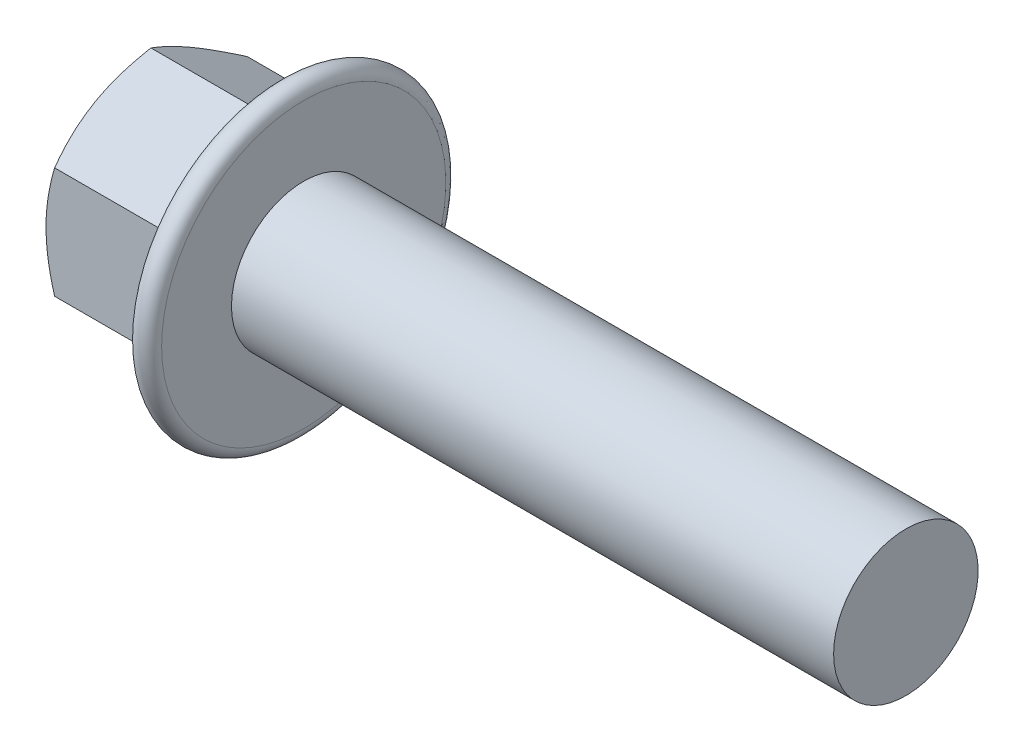
from build123d import *

# Parameters (mm, degrees)
SKETCH2_R         = 4.665127021
HEX_DIE_DEPTH     = 6.7
FLANGEHEXFILLET_R = 0.4
SKETCH4_R         = 3.5
INDENT_DEPTH      = 0.558333333


with BuildPart() as part:
    # BodySke → Base-Revolve (revolve)
    with BuildSketch(Plane.XY, mode=Mode.PRIVATE) as base_revolve_sk:
        Polygon((6.7, 3), (6.7, 4.618937644), (0.357343816, 4.618937644), (0, 4), (0, 0), (31.7, 0), (31.7, 3), align=None)
    revolve(base_revolve_sk.sketch.rotate(Axis((-25.4, 0, 0), (1, 0, 0)), 90), axis=Axis((-25.4, 0, 0), (1, 0, 0)))

    # Sketch2 → Hex-Die (cut)
    with BuildSketch(Plane(origin=(0, 0, 0), x_dir=(0, 0, -1), z_dir=(1, 0, 0))):
        Circle(SKETCH2_R)
        Polygon((-4, 2.309401087), (0, 4.618802174), (4, 2.309401087), (4, -2.309401087), (0, -4.618802174), (-4, -2.309401087), align=None, mode=Mode.SUBTRACT)
    extrude(amount=HEX_DIE_DEPTH, mode=Mode.SUBTRACT)

    # Sketch5 → Flange (revolve)
    with BuildSketch(Plane.XY, mode=Mode.PRIVATE) as flange_sk:
        with BuildLine():
            Line((3.520486732, 0), (5.73015369, 6.071010072))
            ThreePointArc((5.73015369, 6.071010072), (6.286824089, 6.392403877), (6.7, 5.9))
            Line((6.7, 5.9), (6.7, 0))
            Line((6.7, 0), (3.520486732, 0))
        make_face()
    revolve(flange_sk.sketch.rotate(Axis((0, 0, 0), (1, 0, 0)), 90), axis=Axis((0, 0, 0), (1, 0, 0)))

    # FlangeHexFillet
    flangehexfillet_edges = [part.edges().sort_by_distance(p)[0] for p in [
        (5.036325168, 1.159737723, 4),
        (4.976367673, 3.46410163, 2),
        (4.976367673, 3.46410163, -2),
        (4.976367669, 0, -4),
        (4.976367673, -3.46410163, -2),
        (4.976367673, -3.46410163, 2),
        (5.036325168, -1.159737723, 4),
    ]]
    fillet(flangehexfillet_edges, radius=FLANGEHEXFILLET_R)

    # Sketch4 → Indent (cut)
    with BuildSketch(Plane(origin=(0, 0, 0), x_dir=(0, 0, -1), z_dir=(1, 0, 0))):
        Circle(SKETCH4_R)
    extrude(amount=INDENT_DEPTH, mode=Mode.SUBTRACT)


solid = part.part
